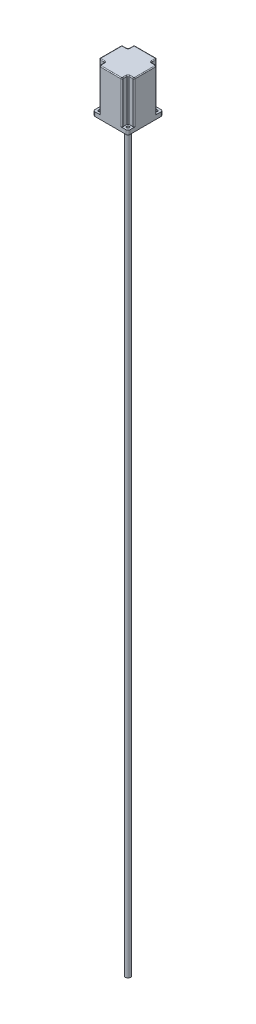
from build123d import *

# Parameters (mm, degrees)
EXTRUDE_1_DEPTH       = 10
EXTRUDE_2_DEPTH       = 104
SKETCH_3_R            = 36.5
EXTRUDE_3_DEPTH       = 2
SKETCH_4_R            = 6.35
EXTRUDE_4_DEPTH       = 35
CUT_EXTRUDE_1_DEPTH   = 25
FILLET_1_R            = 2
HOLE_WIZARD_M61_D     = 6.5
HOLE_WIZARD_M61_DEPTH = 10
SKETCH_10_R           = 6
EXTRUDE_6_DEPTH       = 2
FILLET_2_R            = 1.5
SKETCH_11_R           = 2.22242602
EXTRUDE_7_DEPTH       = 5
SCALE1_SCALE          = 5
SKETCH1_R             = 32.004
BOSS_EXTRUDE1_DEPTH   = 9144


with BuildPart() as part:
    # Эскиз1 → Бобышка-Вытянуть1 (new body)
    with BuildSketch(Plane(origin=(0, 0, 0), x_dir=(1, 0, 0), z_dir=(0, 1, 0))):
        with BuildLine():
            Line((-38, 43), (38, 43))
            ThreePointArc((38, 43), (41.535533906, 41.535533906), (43, 38))
            Line((43, 38), (43, -38))
            ThreePointArc((43, -38), (41.535533906, -41.535533906), (38, -43))
            Line((38, -43), (-38, -43))
            ThreePointArc((-38, -43), (-41.535533906, -41.535533906), (-43, -38))
            Line((-43, -38), (-43, 38))
            ThreePointArc((-43, 38), (-41.535533906, 41.535533906), (-38, 43))
        make_face()
    extrude(amount=EXTRUDE_1_DEPTH)

    # Эскиз2 → Бобышка-Вытянуть2 (add)
    with BuildSketch(Plane(origin=(0, 10, 0), x_dir=(1, 0, 0), z_dir=(0, 1, 0))):
        with BuildLine():
            ThreePointArc((28, 40), (27.121320344, 42.121320344), (25, 43))
            Line((25, 43), (-25, 43))
            ThreePointArc((-25, 43), (-27.121320344, 42.121320344), (-28, 40))
            Line((-28, 40), (-28, 31))
            ThreePointArc((-28, 31), (-28.878679656, 28.878679656), (-31, 28))
            Line((-31, 28), (-40, 28))
            ThreePointArc((-40, 28), (-42.121320344, 27.121320344), (-43, 25))
            Line((-43, 25), (-43, -25))
            ThreePointArc((-43, -25), (-42.121320344, -27.121320344), (-40, -28))
            Line((-40, -28), (-31, -28))
            ThreePointArc((-31, -28), (-28.878679656, -28.878679656), (-28, -31))
            Line((-28, -31), (-28, -40))
            ThreePointArc((-28, -40), (-27.121320344, -42.121320344), (-25, -43))
            Line((-25, -43), (25, -43))
            ThreePointArc((25, -43), (27.121320344, -42.121320344), (28, -40))
            Line((28, -40), (28, -31))
            ThreePointArc((28, -31), (28.878679656, -28.878679656), (31, -28))
            Line((31, -28), (40, -28))
            ThreePointArc((40, -28), (42.121320344, -27.121320344), (43, -25))
            Line((43, -25), (43, 25))
            ThreePointArc((43, 25), (42.121320344, 27.121320344), (40, 28))
            Line((40, 28), (31, 28))
            ThreePointArc((31, 28), (28.878679656, 28.878679656), (28, 31))
            Line((28, 31), (28, 40))
        make_face()
    extrude(amount=EXTRUDE_2_DEPTH)

    # Эскиз3 → Бобышка-Вытянуть3 (add)
    with BuildSketch(Plane.XZ):
        Circle(SKETCH_3_R)
    extrude(amount=EXTRUDE_3_DEPTH)

    # Эскиз4 → Бобышка-Вытянуть4 (add)
    with BuildSketch(Plane.XZ.offset(2)):
        Circle(SKETCH_4_R)
    extrude(amount=EXTRUDE_4_DEPTH)

    # Эскиз6 → Вырез-Вытянуть1 (cut)
    with BuildSketch(Plane.XZ.offset(37)):
        Polygon((-3.085449724, 5.55), (5.55, 5.55), (5.55, -3.085449724), (7.531526378, -3.085449724), (7.531526378, 7.645441362), (-3.085449724, 7.645441362), align=None)
    extrude(amount=-CUT_EXTRUDE_1_DEPTH, mode=Mode.SUBTRACT)

    # Скругление1
    fillet_1_edges = [part.edges().sort_by_distance(p)[0] for p in [
        (42.121320344, 114, -27.121320344),
        (35.5, 114, -28),
        (28, 114, -35.5),
        (-27.121320344, 114, -42.121320344),
        (-42.121320344, 114, 27.121320344),
        (-35.5, 114, 28),
        (-28, 114, 35.5),
        (27.121320344, 114, 42.121320344),
        (28, 114, 35.5),
        (28.878679656, 114, 28.878679656),
        (35.5, 114, 28),
        (42.121320344, 114, 27.121320344),
        (43, 114, 0),
        (28.878679656, 114, -28.878679656),
        (27.121320344, 114, -42.121320344),
        (0, 114, -43),
        (-28, 114, -35.5),
        (-28.878679656, 114, -28.878679656),
        (-35.5, 114, -28),
        (-42.121320344, 114, -27.121320344),
        (-43, 114, 0),
        (-28.878679656, 114, 28.878679656),
        (-27.121320344, 114, 42.121320344),
        (0, 114, 43),
    ]]
    fillet(fillet_1_edges, radius=FILLET_1_R)

    # Отверстие с зазором M61
    with Locations(Plane(origin=(0, 0, 0), x_dir=(-1, 0, 0), z_dir=(0, -1, 0))):
        with Locations((34.8, -34.8), (-34.8, -34.8), (-34.8, 34.8), (34.8, 34.8)):
            Hole(HOLE_WIZARD_M61_D / 2, depth=HOLE_WIZARD_M61_DEPTH)

    # Эскиз10 → Бобышка-Вытянуть6 (add)
    with BuildSketch(Plane(origin=(0, 0, -43), x_dir=(-1, 0, 0), z_dir=(0, 0, -1))):
        with Locations((0, 100.917861996)):
            Circle(SKETCH_10_R)
    extrude(amount=EXTRUDE_6_DEPTH)

    # Скругление2
    fillet_2_edges = [part.edges().sort_by_distance(p)[0] for p in [
        (6, 100.917861996, -45),
    ]]
    fillet(fillet_2_edges, radius=FILLET_2_R)

    # Эскиз11 → Бобышка-Вытянуть7 (add)
    with BuildSketch(Plane(origin=(0, 0, -45), x_dir=(-1, 0, 0), z_dir=(0, 0, -1))):
        with Locations((0, 100.917861996)):
            Circle(SKETCH_11_R)
    extrude(amount=EXTRUDE_7_DEPTH)


with BuildPart() as part_1:
    # Scale1: scaled about (-0.000644288, 55.41262559, -0.017582419)
    add(part.part.scale(SCALE1_SCALE).moved(Location((0.002577152, -221.65050236, 0.070329676))))

    # Sketch1 → Boss-Extrude1 (add)
    with BuildSketch(Plane.XZ.offset(231.65050236)):
        Circle(SKETCH1_R)
    extrude(amount=BOSS_EXTRUDE1_DEPTH)


solid = part_1.part
